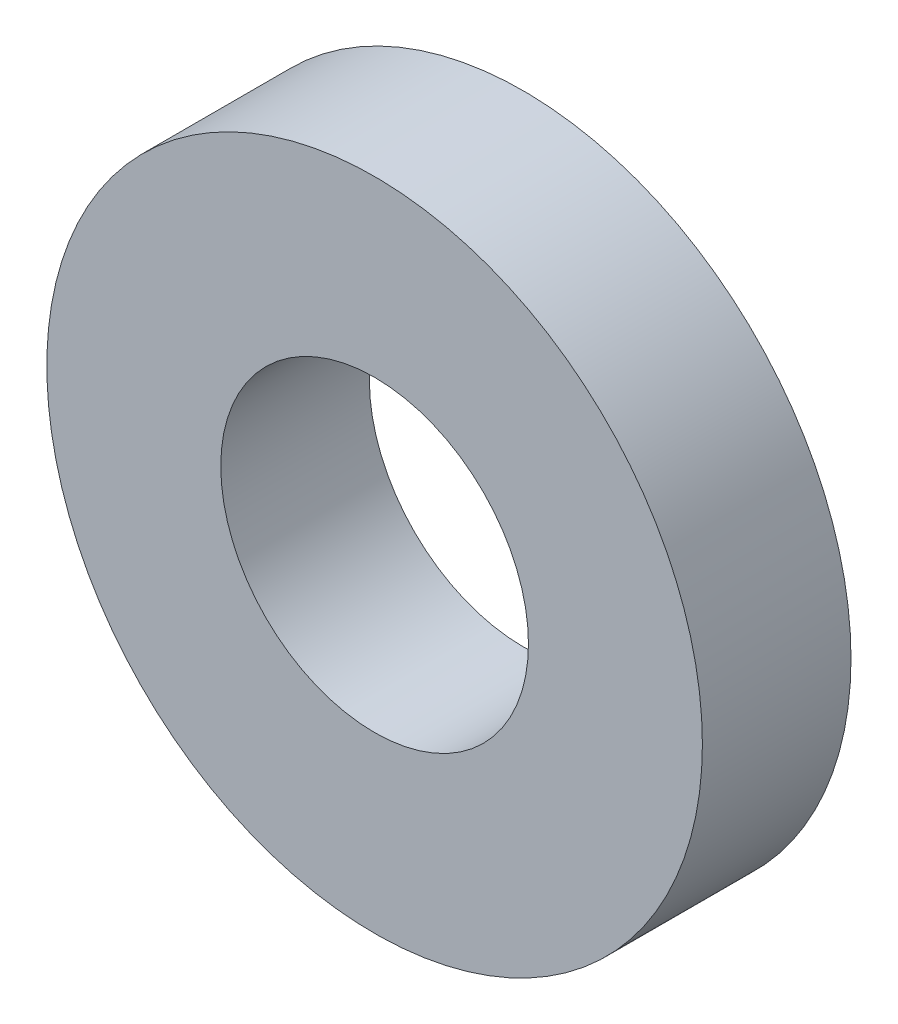
from build123d import *

# Parameters (mm, degrees)
IZIM1_R                     = 37.5
IZIM1_R_2                   = 17.6
Y_KSEKLIK_EKSTR_ZYON1_DEPTH = 8.5


with BuildPart() as part:
    # Çizim1 → Yükseklik-Ekstrüzyon1 (new body, symmetric)
    with BuildSketch(Plane.XY):
        Circle(IZIM1_R)
        Circle(IZIM1_R_2, mode=Mode.SUBTRACT)
    extrude(amount=Y_KSEKLIK_EKSTR_ZYON1_DEPTH, both=True)


solid = part.part
